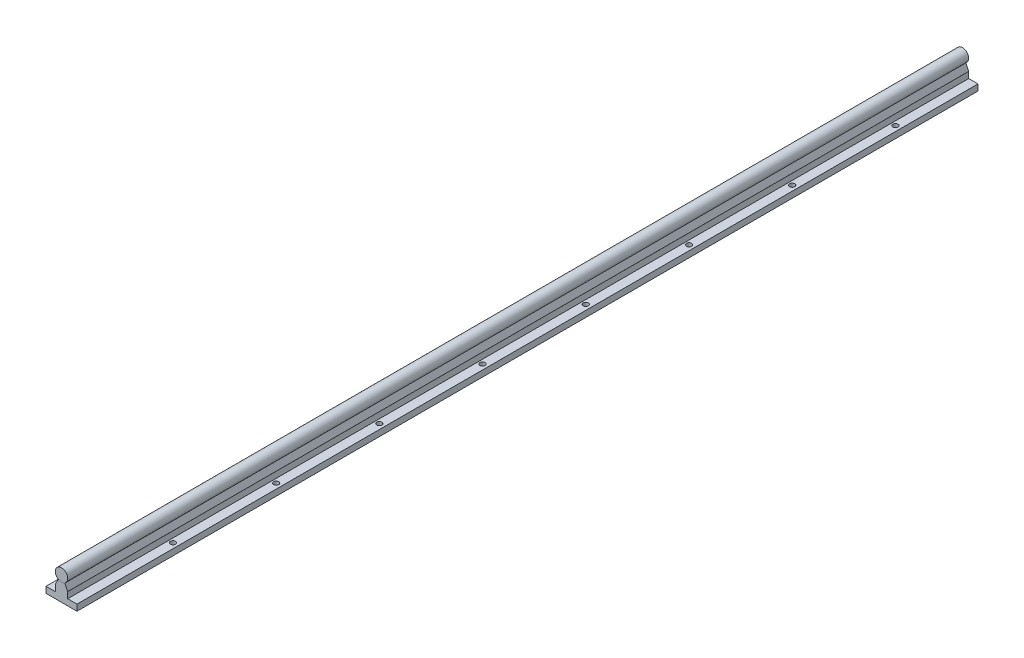
from build123d import *

# Parameters (mm, degrees)
SBS_PROFILE_R             = 6
STEELRAIL_DEPTH           = 873
ALUMINUMSUPPORT_DEPTH     = 873
HOLEDIA_W                 = 2.5
HOLEDIA_H                 = 6.001
MOUNTHOLES_AT_2_COUNT     = 2
MOUNTHOLES_AT_2_PITCH     = 20
LPATTERN1_COUNT           = 8
LPATTERN1_PITCH           = 100
LPATTERN1_COPY_1_SKETCH_W = 2.5
LPATTERN1_COPY_1_SKETCH_H = 6.001
LPATTERN1_COPY_2_SKETCH_W = 2.5
LPATTERN1_COPY_2_SKETCH_H = 6.001
LPATTERN1_COPY_3_SKETCH_W = 2.5
LPATTERN1_COPY_3_SKETCH_H = 6.001
LPATTERN1_COPY_4_SKETCH_W = 2.5
LPATTERN1_COPY_4_SKETCH_H = 6.001
LPATTERN1_COPY_5_SKETCH_W = 2.5
LPATTERN1_COPY_5_SKETCH_H = 6.001
LPATTERN1_COPY_6_SKETCH_W = 2.5
LPATTERN1_COPY_6_SKETCH_H = 6.001
LPATTERN1_COPY_7_SKETCH_W = 2.5
LPATTERN1_COPY_7_SKETCH_H = 6.001


with BuildPart() as part:
    # SBS-Profile → SteelRail (new body)
    with BuildSketch(Plane.XY):
        Circle(SBS_PROFILE_R)
    extrude(amount=STEELRAIL_DEPTH)


with BuildPart() as body_2:
    # SBS-Profile_3 → AluminumSupport (new body)
    with BuildSketch(Plane.XY):
        with BuildLine():
            Line((-15, -17), (-15, -23))
            Line((-15, -23), (15, -23))
            Line((15, -23), (15, -17))
            Line((15, -17), (6, -17))
            Line((6, -17), (6, -11))
            Line((6, -11), (5.962671888, -11))
            Line((5.962671888, -11), (3.2, -5.075431016))
            ThreePointArc((3.2, -5.075431016), (0, -6), (-3.2, -5.075431016))
            Line((-3.2, -5.075431016), (-5.962671888, -11))
            Line((-5.962671888, -11), (-6, -11))
            Line((-6, -11), (-6, -17))
            Line((-6, -17), (-15, -17))
        make_face()
    extrude(amount=ALUMINUMSUPPORT_DEPTH)

    # HoleDia → MountHoles (revolve, cut)
    with BuildSketch(Plane(origin=(10, -23, 75), x_dir=(0, 0, -1), z_dir=(1, 0, 0))):
        with Locations((1.25, 3.0005)):
            Rectangle(HOLEDIA_W, HOLEDIA_H)
    mountholes = revolve(axis=Axis((10, -29.35, 75), (0, 1, 0)), mode=Mode.SUBTRACT)

    # MountHoles at 2: MountHoles ×2
    with Locations(*[(-i * MOUNTHOLES_AT_2_PITCH, 0, 0) for i in range(1, MOUNTHOLES_AT_2_COUNT)]):
        add(mountholes, mode=Mode.SUBTRACT)

    # LPattern1: MountHoles ×8
    with Locations(*[(0, 0, i * LPATTERN1_PITCH) for i in range(1, LPATTERN1_COUNT)]):
        add(mountholes, mode=Mode.SUBTRACT)

    # LPattern1 copy 1 sketch → LPattern1 copy 1 (revolve, cut)
    with BuildSketch(Plane(origin=(-10, -23, 175), x_dir=(0, 0, -1), z_dir=(1, 0, 0))):
        with Locations((1.25, 3.0005)):
            Rectangle(LPATTERN1_COPY_1_SKETCH_W, LPATTERN1_COPY_1_SKETCH_H)
    revolve(axis=Axis((-10, -29.35, 175), (0, 1, 0)), mode=Mode.SUBTRACT)

    # LPattern1 copy 2 sketch → LPattern1 copy 2 (revolve, cut)
    with BuildSketch(Plane(origin=(-10, -23, 275), x_dir=(0, 0, -1), z_dir=(1, 0, 0))):
        with Locations((1.25, 3.0005)):
            Rectangle(LPATTERN1_COPY_2_SKETCH_W, LPATTERN1_COPY_2_SKETCH_H)
    revolve(axis=Axis((-10, -29.35, 275), (0, 1, 0)), mode=Mode.SUBTRACT)

    # LPattern1 copy 3 sketch → LPattern1 copy 3 (revolve, cut)
    with BuildSketch(Plane(origin=(-10, -23, 375), x_dir=(0, 0, -1), z_dir=(1, 0, 0))):
        with Locations((1.25, 3.0005)):
            Rectangle(LPATTERN1_COPY_3_SKETCH_W, LPATTERN1_COPY_3_SKETCH_H)
    revolve(axis=Axis((-10, -29.35, 375), (0, 1, 0)), mode=Mode.SUBTRACT)

    # LPattern1 copy 4 sketch → LPattern1 copy 4 (revolve, cut)
    with BuildSketch(Plane(origin=(-10, -23, 475), x_dir=(0, 0, -1), z_dir=(1, 0, 0))):
        with Locations((1.25, 3.0005)):
            Rectangle(LPATTERN1_COPY_4_SKETCH_W, LPATTERN1_COPY_4_SKETCH_H)
    revolve(axis=Axis((-10, -29.35, 475), (0, 1, 0)), mode=Mode.SUBTRACT)

    # LPattern1 copy 5 sketch → LPattern1 copy 5 (revolve, cut)
    with BuildSketch(Plane(origin=(-10, -23, 575), x_dir=(0, 0, -1), z_dir=(1, 0, 0))):
        with Locations((1.25, 3.0005)):
            Rectangle(LPATTERN1_COPY_5_SKETCH_W, LPATTERN1_COPY_5_SKETCH_H)
    revolve(axis=Axis((-10, -29.35, 575), (0, 1, 0)), mode=Mode.SUBTRACT)

    # LPattern1 copy 6 sketch → LPattern1 copy 6 (revolve, cut)
    with BuildSketch(Plane(origin=(-10, -23, 675), x_dir=(0, 0, -1), z_dir=(1, 0, 0))):
        with Locations((1.25, 3.0005)):
            Rectangle(LPATTERN1_COPY_6_SKETCH_W, LPATTERN1_COPY_6_SKETCH_H)
    revolve(axis=Axis((-10, -29.35, 675), (0, 1, 0)), mode=Mode.SUBTRACT)

    # LPattern1 copy 7 sketch → LPattern1 copy 7 (revolve, cut)
    with BuildSketch(Plane(origin=(-10, -23, 775), x_dir=(0, 0, -1), z_dir=(1, 0, 0))):
        with Locations((1.25, 3.0005)):
            Rectangle(LPATTERN1_COPY_7_SKETCH_W, LPATTERN1_COPY_7_SKETCH_H)
    revolve(axis=Axis((-10, -29.35, 775), (0, 1, 0)), mode=Mode.SUBTRACT)


solid = Compound([part.part, body_2.part])
